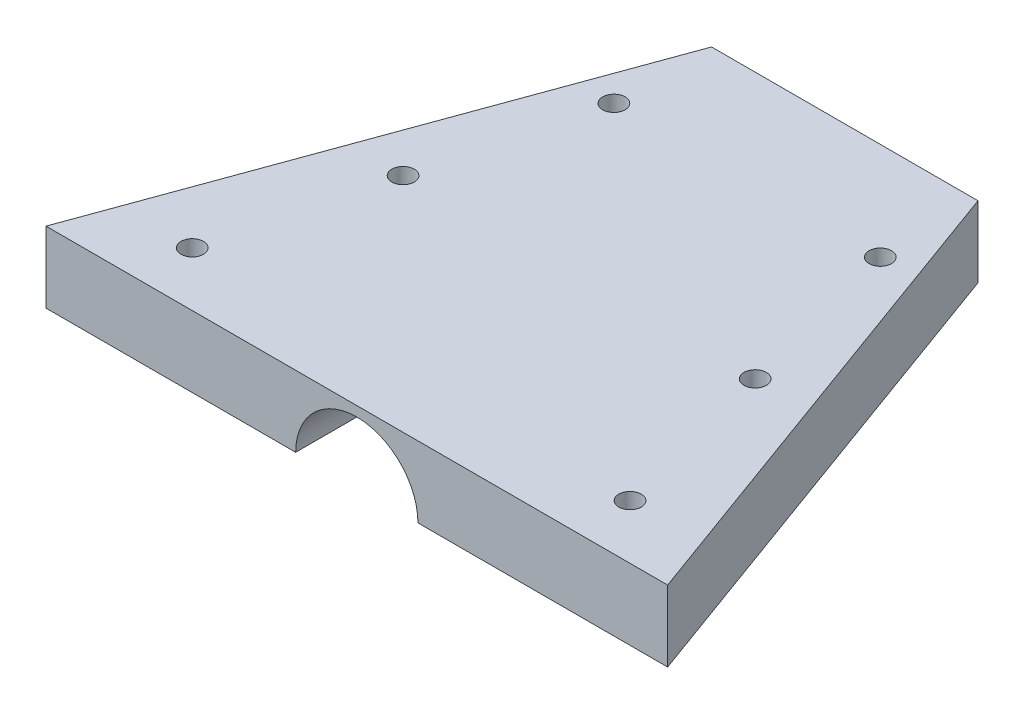
from build123d import *

# Parameters (mm, degrees)
BOSS_EXTRUDE3_DEPTH                    = 8
SKETCH8_R                              = 6.884606738
CUT_EXTRUDE3_DEPTH                     = 88
F_39_0_0995_DIAMETER_HOLE1_D           = 2.5273
F_39_0_0995_DIAMETER_HOLE1_ON_FACE_2_D = 2.5273


with BuildPart() as part:
    # Sketch6 → Boss-Extrude3 (new body)
    with BuildSketch(Plane(origin=(0, 0, 0), x_dir=(1, 0, 0), z_dir=(0, 1, 0))):
        Polygon((-16.836914056, 5.783353512), (13.163085944, 5.783353512), (33.163085944, -49.166194877), (-36.836914056, -49.166194877), align=None)
    extrude(amount=BOSS_EXTRUDE3_DEPTH)

    # Sketch8 → Cut-Extrude3 (cut)
    with BuildSketch(Plane.XY.offset(49.166194877)):
        with Locations((-1.836914056, 0)):
            Circle(SKETCH8_R)
    extrude(amount=-CUT_EXTRUDE3_DEPTH, mode=Mode.SUBTRACT)

    # #39 (0.0995) Diameter Hole1 (through all)
    with Locations(Plane(origin=(17.988085944, 8, 24.13287332), x_dir=(0, 0, 1), z_dir=(0, 1, 0))):
        with Locations((0, 0), (18.916226832, 4.825), (18.916226832, -44.475), (-18.916226832, -34.825), (-18.916226832, -4.825), (0, -39.65)):
            Hole(F_39_0_0995_DIAMETER_HOLE1_D / 2)

    # #39 (0.0995) Diameter Hole1 on face 2 (through all)
    with Locations(Plane(origin=(-16.836914056, 0, 5.216646488), x_dir=(0, 0, -1), z_dir=(0, -1, 0))):
        with Locations((0, 0), (0, 30), (-37.832453664, 39.65), (-37.832453664, -9.65)):
            Hole(F_39_0_0995_DIAMETER_HOLE1_ON_FACE_2_D / 2)


solid = part.part
